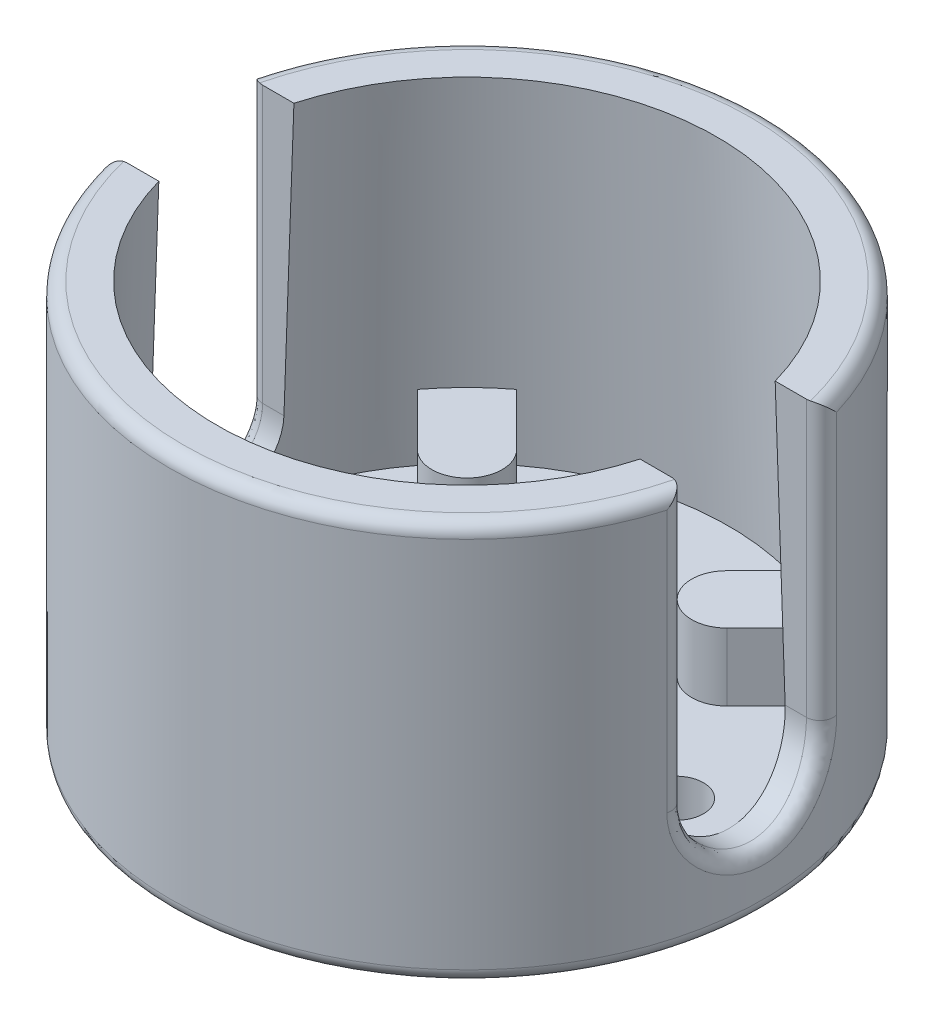
from build123d import *

# Parameters (mm, degrees)
SKETCH1_R           = 11
BOSS_EXTRUDE1_DEPTH = 14.8
SKETCH2_R           = 9.25
CUT_EXTRUDE1_DEPTH  = 12.7
CUT_EXTRUDE1_TAPER  = -2
CUT_EXTRUDE2_REACH  = 4.1
SKETCH3_R           = 5.5
BOSS_EXTRUDE2_DEPTH = 2.5
CUT_EXTRUDE3_DEPTH  = 23
CUT_EXTRUDE4_REACH  = 16.8
SKETCH7_R           = 1
FILLET1_R           = 0.5


with BuildPart() as part:
    # Sketch1 → Boss-Extrude1 (new body)
    with BuildSketch(Plane(origin=(0, 0, 0), x_dir=(1, 0, 0), z_dir=(0, 1, 0))):
        Circle(SKETCH1_R)
    extrude(amount=BOSS_EXTRUDE1_DEPTH)

    # Sketch2 → Cut-Extrude1 (cut)
    with BuildSketch(Plane(origin=(0, 14.8, 0), x_dir=(1, 0, 0), z_dir=(0, 1, 0))):
        Circle(SKETCH2_R)
    extrude(amount=-CUT_EXTRUDE1_DEPTH, taper=CUT_EXTRUDE1_TAPER, mode=Mode.SUBTRACT)

    # Sketch3 → Cut-Extrude2 (cut, up to next)
    with BuildSketch(Plane(origin=(0, 2.1, 0), x_dir=(1, 0, 0), z_dir=(0, 1, 0)), mode=Mode.PRIVATE) as cut_extrude2_sk1:
        Circle(SKETCH3_R)
    cut_extrude2_tool1 = extrude(cut_extrude2_sk1.sketch, amount=-CUT_EXTRUDE2_REACH, mode=Mode.PRIVATE) & part.part
    add(cut_extrude2_tool1.solids().sort_by_distance((0, 2.1, 0))[0], mode=Mode.SUBTRACT)

    # Sketch4 → Boss-Extrude2 (add)
    with BuildSketch(Plane(origin=(0, 2.1, 0), x_dir=(1, 0, 0), z_dir=(0, 1, 0))):
        with BuildLine():
            Line((3.889087297, 5.727564928), (5.873176864, 7.711654495))
            ThreePointArc((5.873176864, 7.711654495), (6.85433518, 6.85433518), (7.711654495, 5.873176864))
            Line((7.711654495, 5.873176864), (5.727564928, 3.889087297))
            ThreePointArc((5.727564928, 3.889087297), (3.889087297, 3.889087297), (3.889087297, 5.727564928))
        make_face()
        with BuildLine():
            Line((3.889087297, -5.727564928), (5.873176864, -7.711654495))
            ThreePointArc((5.873176864, -7.711654495), (6.85433518, -6.85433518), (7.711654495, -5.873176864))
            Line((7.711654495, -5.873176864), (5.727564928, -3.889087297))
            ThreePointArc((5.727564928, -3.889087297), (3.889087297, -3.889087297), (3.889087297, -5.727564928))
        make_face()
        with BuildLine():
            Line((-5.727564928, -3.889087297), (-7.711654495, -5.873176864))
            ThreePointArc((-7.711654495, -5.873176864), (-6.85433518, -6.85433518), (-5.873176864, -7.711654495))
            Line((-5.873176864, -7.711654495), (-3.889087297, -5.727564928))
            ThreePointArc((-3.889087297, -5.727564928), (-3.889087297, -3.889087297), (-5.727564928, -3.889087297))
        make_face()
        with BuildLine():
            Line((-3.889087297, 5.727564928), (-5.873176864, 7.711654495))
            ThreePointArc((-5.873176864, 7.711654495), (-6.85433518, 6.85433518), (-7.711654495, 5.873176864))
            Line((-7.711654495, 5.873176864), (-5.727564928, 3.889087297))
            ThreePointArc((-5.727564928, 3.889087297), (-3.889087297, 3.889087297), (-3.889087297, 5.727564928))
        make_face()
    extrude(amount=BOSS_EXTRUDE2_DEPTH)

    # Sketch6 → Cut-Extrude3 (cut, through all)
    with BuildSketch(Plane.ZY.offset(11)):
        with BuildLine():
            Line((-2.5, 4.6), (-2.5, 14.8))
            Line((-2.5, 14.8), (2.5, 14.8))
            Line((2.5, 14.8), (2.5, 4.6))
            ThreePointArc((2.5, 4.6), (0, 2.1), (-2.5, 4.6))
        make_face()
    extrude(amount=-CUT_EXTRUDE3_DEPTH, mode=Mode.SUBTRACT)

    # Sketch7 → Cut-Extrude4 (cut, up to next)
    with BuildSketch(Plane.XZ, mode=Mode.PRIVATE) as cut_extrude4_sk1:
        with Locations((7.75, 0)):
            Circle(SKETCH7_R)
    cut_extrude4_tool1 = extrude(cut_extrude4_sk1.sketch, amount=-CUT_EXTRUDE4_REACH, mode=Mode.PRIVATE) & part.part
    add(cut_extrude4_tool1.solids().sort_by_distance((7.75, 0, 0))[0], mode=Mode.SUBTRACT)
    # Sketch7 → Cut-Extrude4 (cut, up to next)
    with BuildSketch(Plane.XZ, mode=Mode.PRIVATE) as cut_extrude4_sk2:
        with Locations((-7.75, 0)):
            Circle(SKETCH7_R)
    cut_extrude4_tool2 = extrude(cut_extrude4_sk2.sketch, amount=-CUT_EXTRUDE4_REACH, mode=Mode.PRIVATE) & part.part
    add(cut_extrude4_tool2.solids().sort_by_distance((-7.75, 0, 0))[0], mode=Mode.SUBTRACT)

    # Fillet1
    fillet1_edges = [part.edges().sort_by_distance(p)[0] for p in [
        (-11, 0, 0),
        (0, 14.8, -11),
        (0, 14.8, 11),
        (-10.712142643, 9.7, -2.5),
        (10.712142643, 9.7, -2.5),
        (-10.712142643, 9.7, 2.5),
        (10.712142643, 9.7, 2.5),
        (10.857017021, 2.832284274, 1.767818206),
        (-11, 2.1, 0),
    ]]
    fillet(fillet1_edges, radius=FILLET1_R)


solid = part.part
